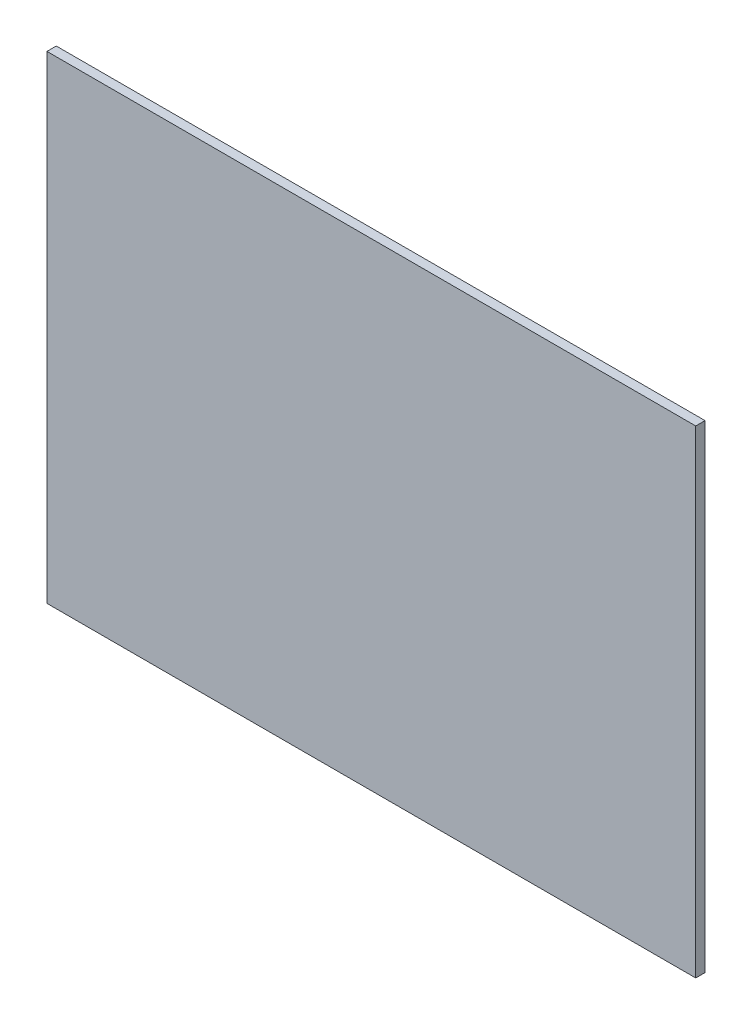
from build123d import *

# Parameters (mm, degrees)
SKETCH1_W           = 418
SKETCH1_H           = 308
BOSS_EXTRUDE1_DEPTH = 6


with BuildPart() as part:
    # Sketch1 → Boss-Extrude1 (new body)
    with BuildSketch(Plane.XY):
        with Locations((209, 154)):
            Rectangle(SKETCH1_W, SKETCH1_H)
    extrude(amount=BOSS_EXTRUDE1_DEPTH)


solid = part.part
